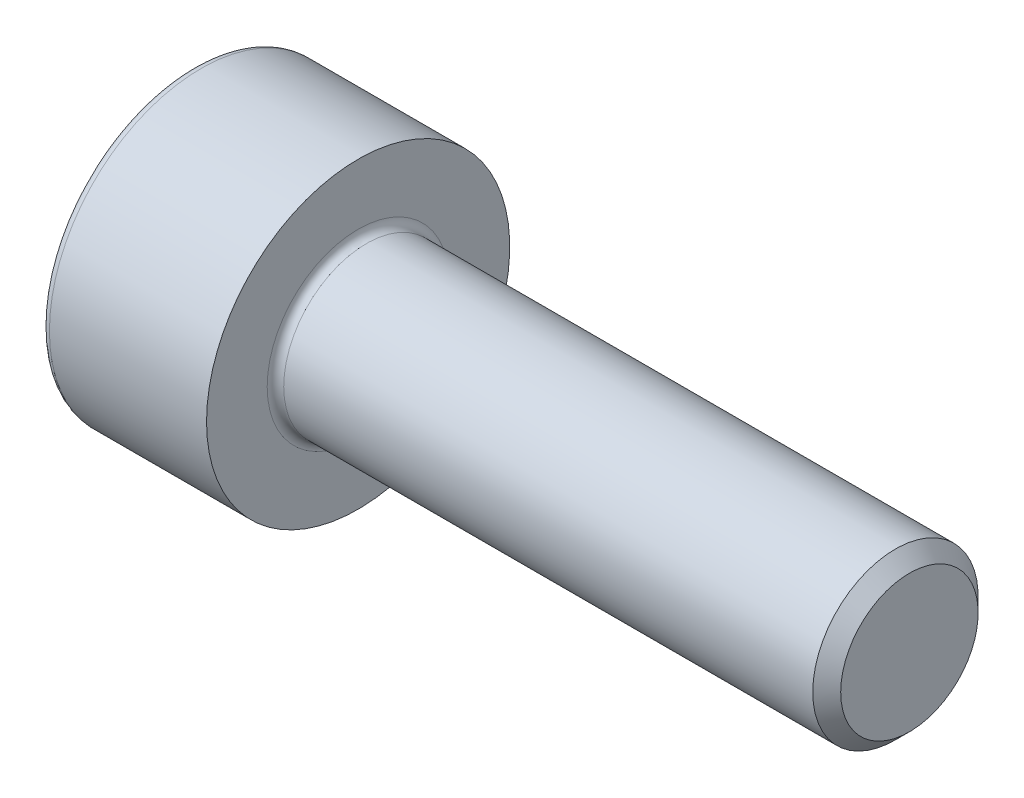
from build123d import *

# Parameters (mm, degrees)
CUT_EXTRUDE1_DEPTH = 1.3


with BuildPart() as part:
    # Sketch1 → Revolve1 (revolve)
    with BuildSketch(Plane.XY):
        with BuildLine():
            Line((9.7465, 1.5), (0.15, 1.5))
            ThreePointArc((0.15, 1.5), (0.043933983, 1.543933983), (0, 1.65))
            Line((0, 1.65), (0, 2.75))
            Line((0, 2.75), (-2.85, 2.75))
            ThreePointArc((-2.85, 2.75), (-2.956066017, 2.706066017), (-3, 2.6))
            Line((-3, 2.6), (-3, 0))
            Line((-3, 0), (10, 0))
            Line((10, 0), (10, 1.2465))
            Line((10, 1.2465), (9.7465, 1.5))
        make_face()
    revolve(axis=Axis((-3, 0, 0), (1, 0, 0)))

    # Sketch2 → Cut-Extrude1 (cut)
    with BuildSketch(Plane.ZY.offset(3)):
        Polygon((1.28, 0.739008345), (0, 1.478016689), (-1.28, 0.739008345), (-1.28, -0.739008345), (0, -1.478016689), (1.28, -0.739008345), align=None)
    extrude(amount=-CUT_EXTRUDE1_DEPTH, mode=Mode.SUBTRACT)


solid = part.part
